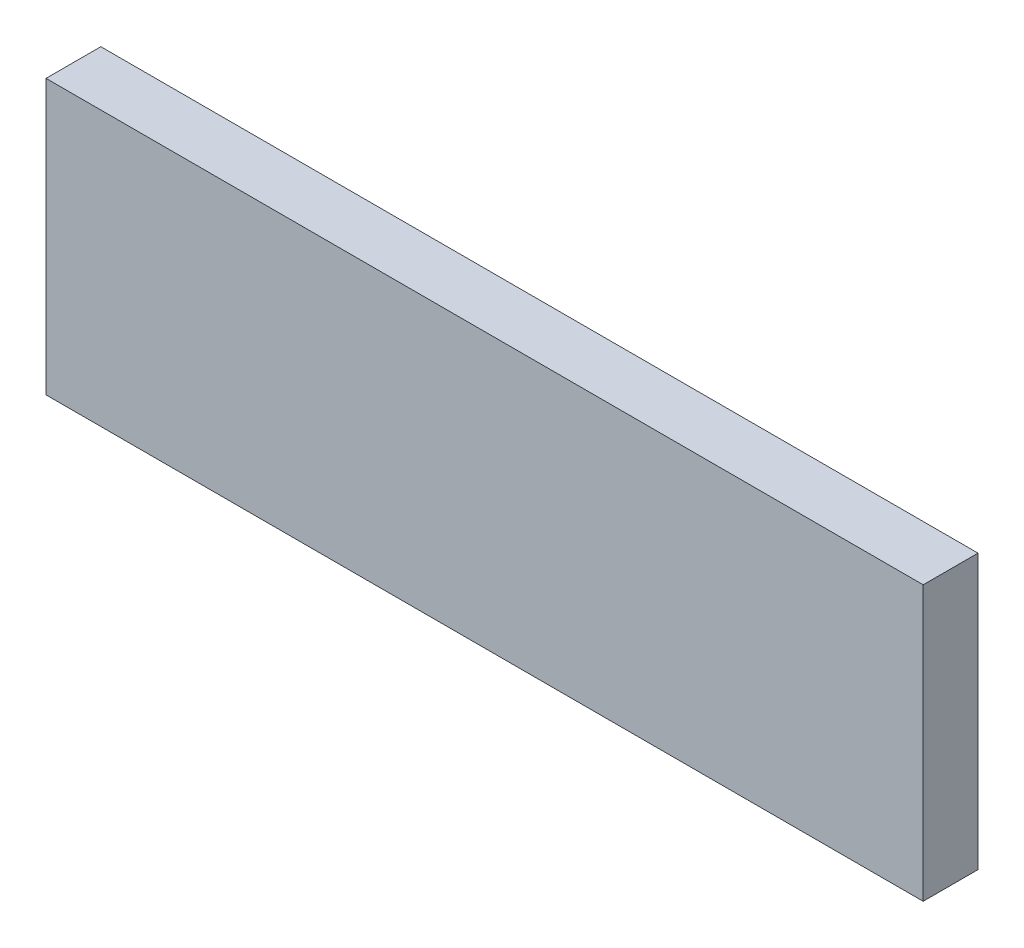
from build123d import *

# Parameters (mm, degrees)
SKETCH_1_W      = 160
SKETCH_1_H      = 50
EXTRUDE_1_DEPTH = 10


with BuildPart() as part:
    # ｽｹｯﾁ1 → ﾎﾞｽ - 押し出し1 (new body)
    with BuildSketch(Plane.XY):
        with Locations((12.271152895, -18.945841393)):
            Rectangle(SKETCH_1_W, SKETCH_1_H)
    extrude(amount=EXTRUDE_1_DEPTH)


solid = part.part
